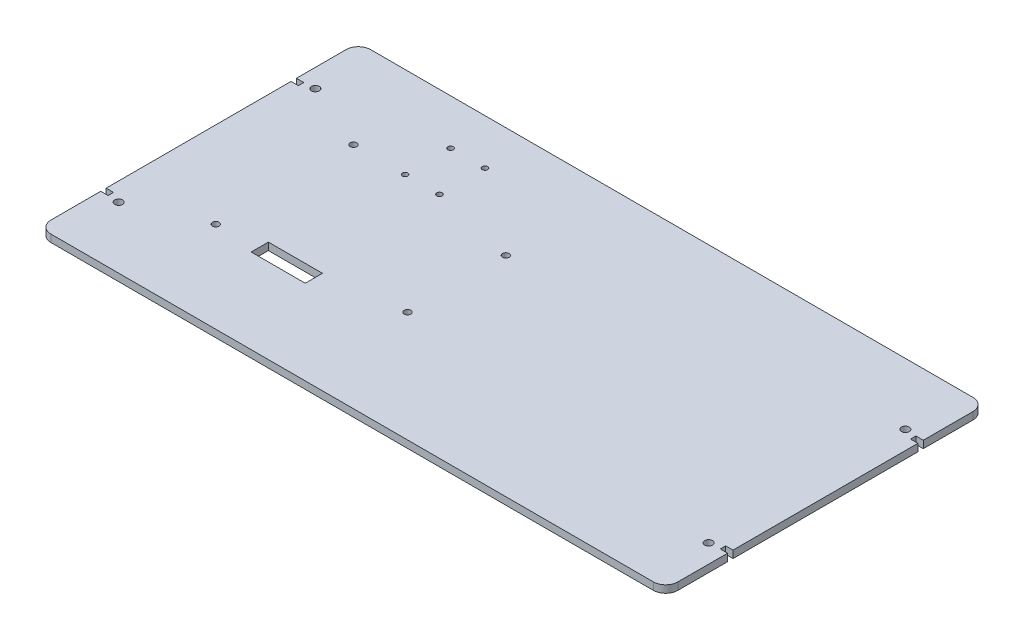
from build123d import *

# Parameters (mm, degrees)
SKETCH1_R           = 1.35
SKETCH1_R_2         = 1.6
SKETCH1_R_3         = 1.1
SKETCH1_W           = 22
SKETCH1_H           = 7
BOSS_EXTRUDE1_DEPTH = 3
FILLET1_R           = 5


with BuildPart() as part:
    # Sketch1 → Boss-Extrude1 (new body)
    with BuildSketch(Plane(origin=(0, 0, 0), x_dir=(1, 0, 0), z_dir=(0, 1, 0))):
        Polygon((-127.5, 65), (127.5, 65), (127.5, 39.8), (124.5, 39.8), (124.5, 37.6), (127.5, 37.6), (127.5, -37.6), (124.5, -37.6), (124.5, -39.8), (127.5, -39.8), (127.5, -65), (-127.5, -65), (-127.5, -39.8), (-124.5, -39.8), (-124.5, -37.6), (-127.5, -37.6), (-127.5, 37.6), (-124.5, 37.6), (-124.5, 39.8), (-127.5, 39.8), align=None)
        with Locations((-92.5, 28)):
            Circle(SKETCH1_R, mode=Mode.SUBTRACT)
        with Locations((-22.5, 20)):
            Circle(SKETCH1_R, mode=Mode.SUBTRACT)
        with Locations((-92.5, -28)):
            Circle(SKETCH1_R, mode=Mode.SUBTRACT)
        with Locations((-22.5, -20)):
            Circle(SKETCH1_R, mode=Mode.SUBTRACT)
        with Locations((-120, 40)):
            Circle(SKETCH1_R_2, mode=Mode.SUBTRACT)
        with Locations((120, 40)):
            Circle(SKETCH1_R_2, mode=Mode.SUBTRACT)
        with Locations((120, -40)):
            Circle(SKETCH1_R_2, mode=Mode.SUBTRACT)
        with Locations((-120, -40)):
            Circle(SKETCH1_R_2, mode=Mode.SUBTRACT)
        with Locations((-71.5, 46.5)):
            Circle(SKETCH1_R_3, mode=Mode.SUBTRACT)
        with Locations((-71.5, 28)):
            Circle(SKETCH1_R_3, mode=Mode.SUBTRACT)
        with Locations((-57.5, 46.5)):
            Circle(SKETCH1_R_3, mode=Mode.SUBTRACT)
        with Locations((-57.5, 28)):
            Circle(SKETCH1_R_3, mode=Mode.SUBTRACT)
        with Locations((-64.5, -27.1)):
            Rectangle(SKETCH1_W, SKETCH1_H, mode=Mode.SUBTRACT)
    extrude(amount=BOSS_EXTRUDE1_DEPTH)

    # Fillet1
    fillet1_edges = [part.edges().sort_by_distance(p)[0] for p in [
        (127.5, 1.5, 65),
        (-127.5, 1.5, 65),
        (-127.5, 1.5, -65),
        (127.5, 1.5, -65),
    ]]
    fillet(fillet1_edges, radius=FILLET1_R)


solid = part.part
